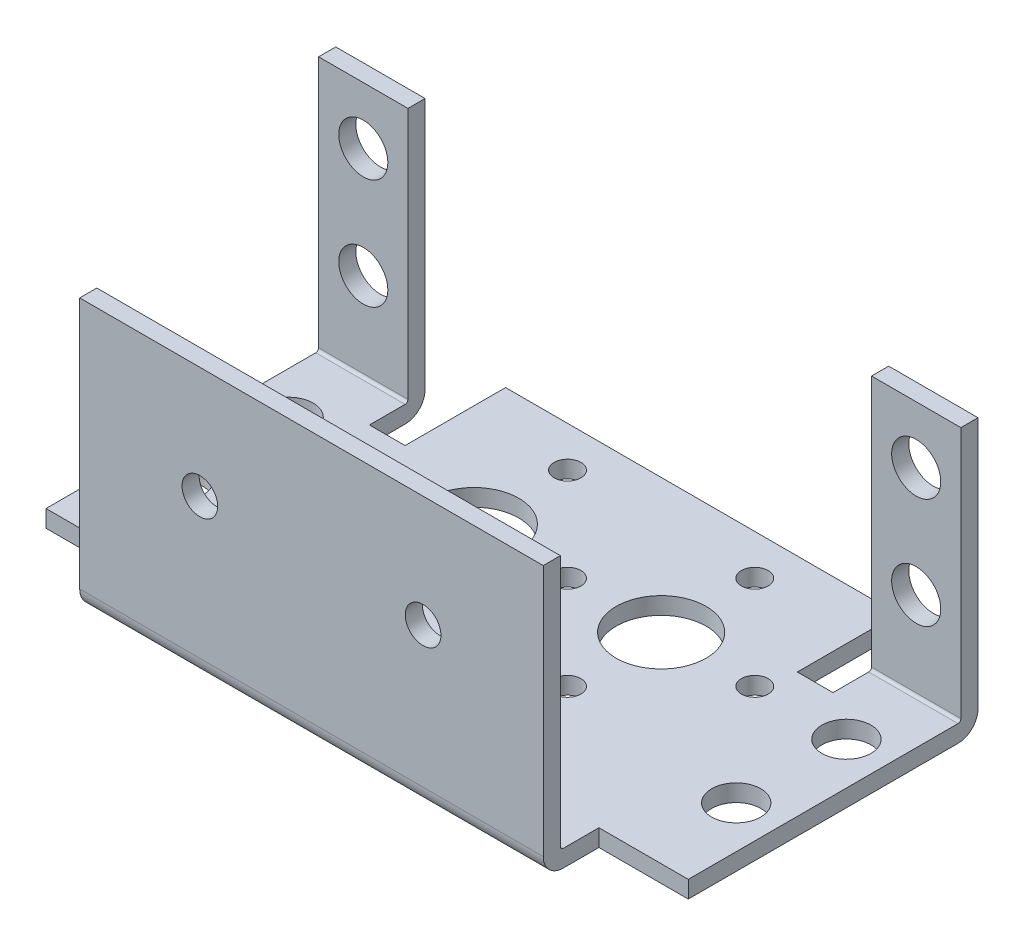
from build123d import *

# Parameters (mm, degrees)
SKETCH1_R      = 1.1938
SKETCH1_R_2    = 2.1844
SKETCH1_R_3    = 4.0005
EXTRUDE1_DEPTH = 1.524
EXTRUDE3_START = -13.3731
SKETCH3_W      = 7.9502
SKETCH3_H      = 24.2062
SKETCH3_R      = 2.1844
EXTRUDE3_DEPTH = 1.524
EXTRUDE4_START = 15.8369
SKETCH3_3_W    = 41.2496
SKETCH3_3_H    = 24.2062
SKETCH3_3_R    = 1.5875
EXTRUDE4_DEPTH = 1.524
FILLET4_R      = 1.778
FILLET5_R      = 0.254


with BuildPart() as part:
    # Sketch1 → Extrude1 (new body)
    with BuildSketch(Plane(origin=(0, 0, 0), x_dir=(1, 0, 0), z_dir=(0, 1, 0))):
        Polygon((28.575, 0), (28.575, -12.4079), (20.6248, -12.4079), (20.6248, -17.3609), (-20.6248, -17.3609), (-20.6248, -12.4079), (-28.575, -12.4079), (-28.575, 0), align=None)
        with Locations(Location((8.3312, -2.9083, 0), (0, 0, 270))):  # turned: the seam where the file's is
            Circle(SKETCH1_R, mode=Mode.SUBTRACT)
        with Locations(Location((-8.3312, -2.9083, 0), (0, 0, 270))):  # turned: the seam where the file's is
            Circle(SKETCH1_R, mode=Mode.SUBTRACT)
        with Locations(Location((-24.8158, -4.3815, 0), (0, 0, 270))):  # turned: the seam where the file's is
            Circle(SKETCH1_R_2, mode=Mode.SUBTRACT)
        with Locations(Location((24.8158, -4.3815, 0), (0, 0, 270))):  # turned: the seam where the file's is
            Circle(SKETCH1_R_2, mode=Mode.SUBTRACT)
        Polygon((28.575, 0), (-28.575, 0), (-28.575, 13.3731), (-20.6248, 13.3731), (-20.6248, 8.4201), (-17.4498, 8.4201), (-17.4498, 17.3609), (17.4498, 17.3609), (17.4498, 8.4201), (20.6248, 8.4201), (20.6248, 13.3731), (28.575, 13.3731), align=None)
        with Locations(Location((8.3312, 5.4229, 0), (0, 0, 270))):  # turned: the seam where the file's is
            Circle(SKETCH1_R_3, mode=Mode.SUBTRACT)
        with Locations(Location((8.3312, 13.7541, 0), (0, 0, 270))):  # turned: the seam where the file's is
            Circle(SKETCH1_R, mode=Mode.SUBTRACT)
        with Locations(Location((-8.3312, 5.4229, 0), (0, 0, 270))):  # turned: the seam where the file's is
            Circle(SKETCH1_R_3, mode=Mode.SUBTRACT)
        with Locations(Location((-24.8158, 5.4229, 0), (0, 0, 270))):  # turned: the seam where the file's is
            Circle(SKETCH1_R_2, mode=Mode.SUBTRACT)
        with Locations(Location((-16.6624, 5.4229, 0), (0, 0, 270))):  # turned: the seam where the file's is
            Circle(SKETCH1_R, mode=Mode.SUBTRACT)
        with Locations(Location((-8.3312, 13.7541, 0), (0, 0, 270))):  # turned: the seam where the file's is
            Circle(SKETCH1_R, mode=Mode.SUBTRACT)
        with Locations(Location((0, 5.4229, 0), (0, 0, 270))):  # turned: the seam where the file's is
            Circle(SKETCH1_R, mode=Mode.SUBTRACT)
        with Locations(Location((16.6624, 5.4229, 0), (0, 0, 270))):  # turned: the seam where the file's is
            Circle(SKETCH1_R, mode=Mode.SUBTRACT)
        with Locations(Location((24.8158, 5.4229, 0), (0, 0, 270))):  # turned: the seam where the file's is
            Circle(SKETCH1_R_2, mode=Mode.SUBTRACT)
    extrude(amount=EXTRUDE1_DEPTH)

    # Sketch3 → Extrude3 (add)
    with BuildSketch(Plane.XY.offset(EXTRUDE3_START)):
        with Locations((-24.5999, 12.1031)):
            Rectangle(SKETCH3_W, SKETCH3_H)
        with Locations((-24.5999, 19.1262)):
            Circle(SKETCH3_R, mode=Mode.SUBTRACT)
        with Locations((-24.5999, 9.3218)):
            Circle(SKETCH3_R, mode=Mode.SUBTRACT)
        with Locations((24.5999, 12.1031)):
            Rectangle(SKETCH3_W, SKETCH3_H)
        with Locations((24.5999, 9.3218)):
            Circle(SKETCH3_R, mode=Mode.SUBTRACT)
        with Locations((24.5999, 19.1262)):
            Circle(SKETCH3_R, mode=Mode.SUBTRACT)
    extrude(amount=EXTRUDE3_DEPTH)

    # Sketch3_3 → Extrude4 (add)
    with BuildSketch(Plane.XY.offset(EXTRUDE4_START)):
        with Locations((0, 12.1031)):
            Rectangle(SKETCH3_3_W, SKETCH3_3_H)
        with Locations((-9.9314, 14.2748)):
            Circle(SKETCH3_3_R, mode=Mode.SUBTRACT)
        with Locations((9.9314, 14.2748)):
            Circle(SKETCH3_3_R, mode=Mode.SUBTRACT)
    extrude(amount=EXTRUDE4_DEPTH)

    # Fillet4
    fillet4_edges = [part.edges().sort_by_distance(p)[0] for p in [
        (0, 0, 17.3609),
        (-24.5999, 0, -13.3731),
        (24.5999, 0, -13.3731),
    ]]
    fillet(fillet4_edges, radius=FILLET4_R)

    # Fillet5
    fillet5_edges = [part.edges().sort_by_distance(p)[0] for p in [
        (24.5999, 1.524, -11.8491),
        (0, 1.524, 15.8369),
        (-24.5999, 1.524, -11.8491),
    ]]
    fillet(fillet5_edges, radius=FILLET5_R)


solid = part.part
